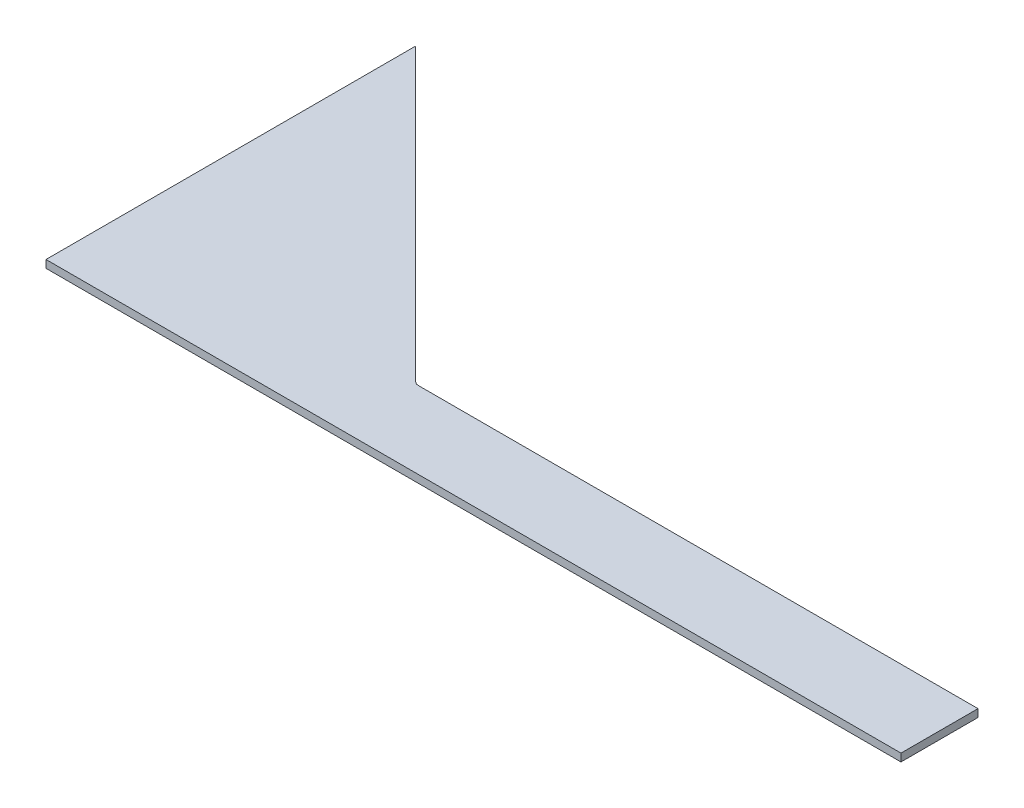
from build123d import *

# Parameters (mm, degrees)
BOSS_EXTRUDE1_DEPTH = 3.175
FILLET1_R           = 2.54


with BuildPart() as part:
    # Sketch1 → Boss-Extrude1 (new body)
    with BuildSketch(Plane(origin=(0, 0, 0), x_dir=(1, 0, 0), z_dir=(0, 1, 0))):
        Polygon((152.4, 0), (0, 0), (0, 152.4), align=None)
        Polygon((120.65, 31.75), (152.4, 0), (352.425, 0), (352.425, 31.75), (121.965128061, 31.75), align=None)
    extrude(amount=BOSS_EXTRUDE1_DEPTH)

    # Fillet1
    fillet1_edges = [part.edges().sort_by_distance(p)[0] for p in [
        (120.65, 1.5875, -31.75),
    ]]
    fillet(fillet1_edges, radius=FILLET1_R)


solid = part.part
